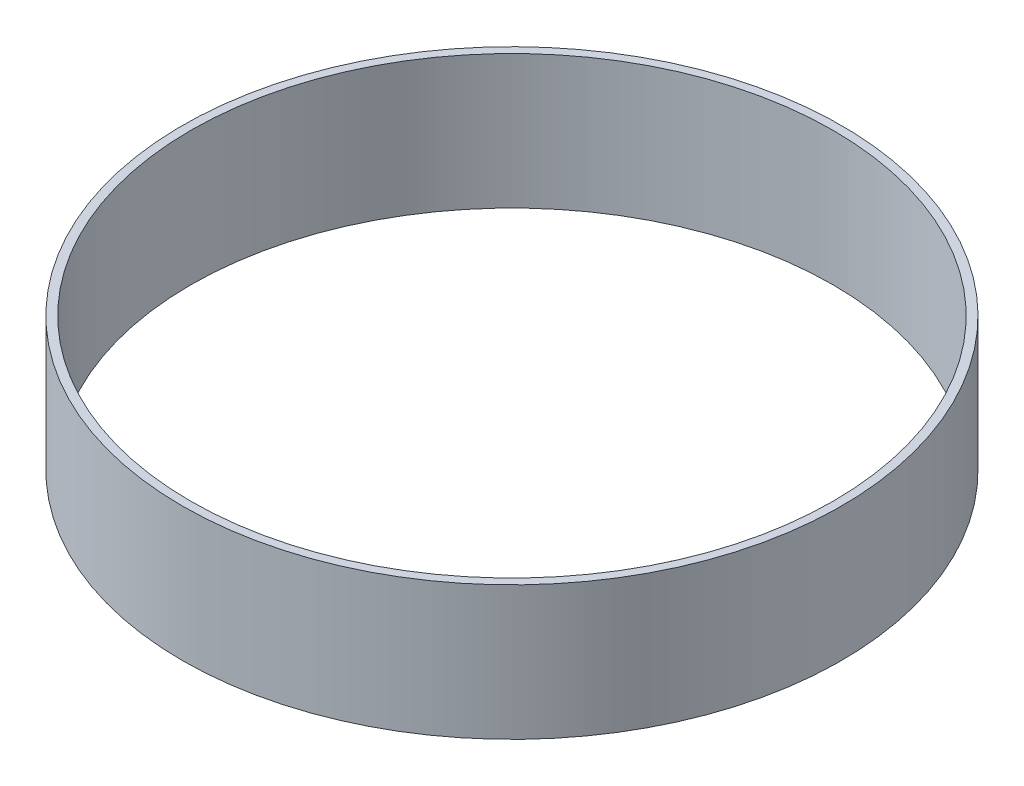
from build123d import *

# Parameters (mm, degrees)
SKETCH1_R           = 98.5
SKETCH1_R_2         = 96
BOSS_EXTRUDE1_DEPTH = 40


with BuildPart() as part:
    # Sketch1 → Boss-Extrude1 (new body)
    with BuildSketch(Plane(origin=(0, 0, 0), x_dir=(1, 0, 0), z_dir=(0, 1, 0))):
        Circle(SKETCH1_R)
        Circle(SKETCH1_R_2, mode=Mode.SUBTRACT)
    extrude(amount=BOSS_EXTRUDE1_DEPTH)


solid = part.part
